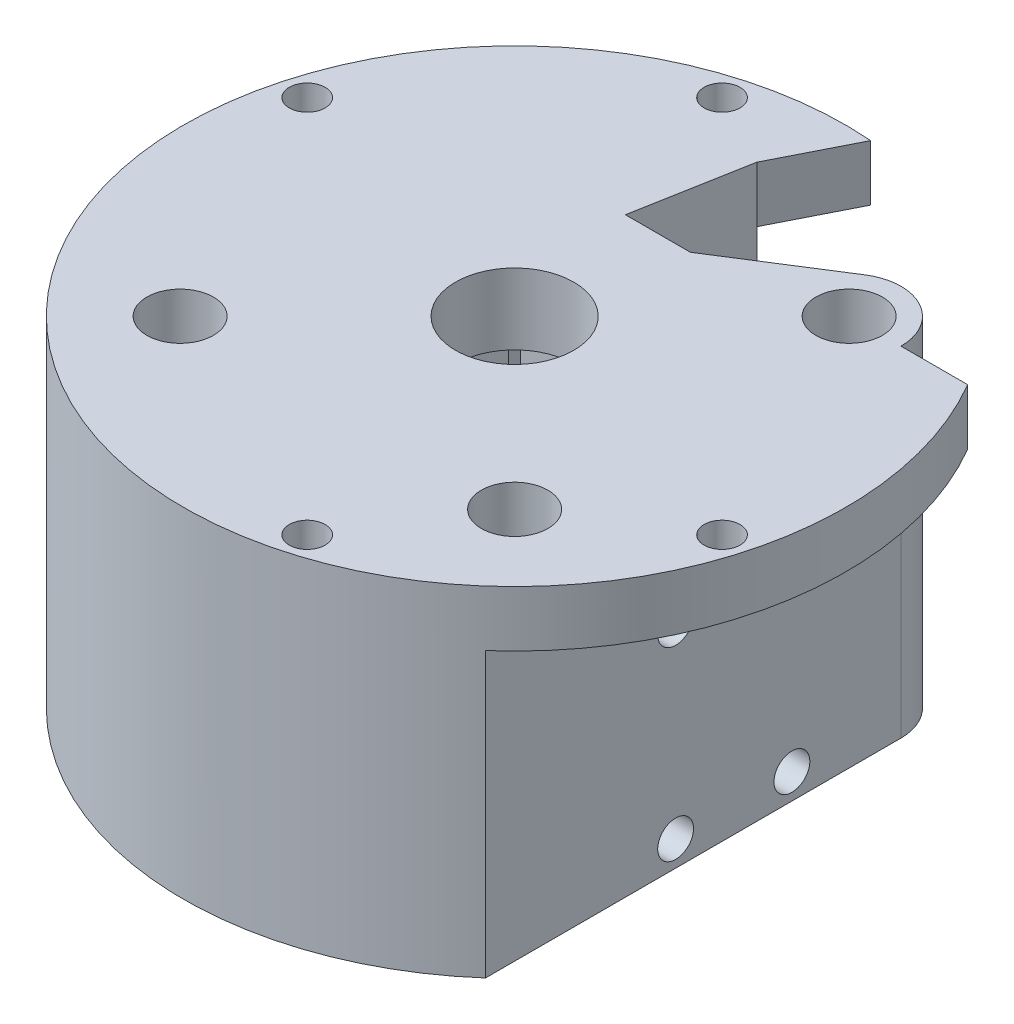
from build123d import *
from build123d.topology import SkipClean

# Parameters (mm, degrees)
SKETCH2_R           = 3.571875
BOSS_EXTRUDE1_DEPTH = 1.905
SKETCH3_R           = 3.571875
BOSS_EXTRUDE2_DEPTH = 19.558
SKETCH4_R           = 3.571875
BOSS_EXTRUDE3_DEPTH = 7.366
SKETCH5_R           = 3.571875
BOSS_EXTRUDE4_DEPTH = 7.62
SKETCH6_R           = 1.925
CUT_EXTRUDE1_DEPTH  = 5.75
BOSS_EXTRUDE5_START = -6
BOSS_EXTRUDE5_DEPTH = 6
SKETCH7_R           = 1.925
CUT_EXTRUDE2_DEPTH  = 5.75


with BuildPart() as part:
    # Sketch2 → Boss-Extrude1 (new body)
    with BuildSketch(Plane(origin=(0, 0, 0), x_dir=(1, 0, 0), z_dir=(0, 1, 0))):
        with BuildLine():
            Line((10.05, -30.05), (-10.05, -30.05))
            Line((-10.05, -30.05), (-10.05, 10.05))
            Line((-10.05, 10.05), (-3.4925, 10.05))
            Line((-3.4925, 10.05), (-3.4925, 15.384))
            Line((-3.4925, 15.384), (-1.318232079, 27.330889022))
            Line((-1.318232079, 27.330889022), (-10.839769253, 32.141975578))
            Line((-10.839769253, 32.141975578), (-12.849275114, 33.15734804))
            ThreePointArc((-12.849275114, 33.15734804), (-30.38177824, -18.478667457), (23.532387242, -26.659714002))
            Line((23.532387242, -26.659714002), (23.532387242, -17.960512242))
            Line((23.532387242, -17.960512242), (23.532387242, 17.960512242))
            ThreePointArc((23.532387242, 17.960512242), (20.645690581, 22.842684741), (14.976700581, 22.666110928))
            Line((14.976700581, 22.666110928), (3.4925, 15.384))
            Line((3.4925, 15.384), (3.4925, 10.05))
            Line((3.4925, 10.05), (10.05, 10.05))
            Line((10.05, 10.05), (10.05, -30.05))
        make_face()
        with Locations(Location((17.960512242, 17.960512242, 0), (0, 0, 90))):
            Circle(SKETCH2_R, mode=Mode.SUBTRACT)
        with Locations(Location((17.960512242, -17.960512242, 0), (0, 0, 90))):
            Circle(SKETCH2_R, mode=Mode.SUBTRACT)
        with Locations(Location((-17.960512242, -17.960512242, 0), (0, 0, 90))):
            Circle(SKETCH2_R, mode=Mode.SUBTRACT)
    extrude(amount=BOSS_EXTRUDE1_DEPTH)

    # Sketch3 → Boss-Extrude2 (add)
    # profile 1 of 2: a face of its own
    with SkipClean():  # the faces are left unmerged after this step: merging them gives an invalid solid
        with BuildSketch(Plane(origin=(0, 1.905, 0), x_dir=(1, 0, 0), z_dir=(0, 1, 0))):
            with BuildLine():
                Line((-10.839769253, 32.141975578), (-32.833307795, -11.385051501))
                Line((-32.833307795, -11.385051501), (-23.311770621, -16.196138057))
                Line((-23.311770621, -16.196138057), (-10.3363742, 9.483241835))
                ThreePointArc((-10.3363742, 9.483241835), (-10.197196408, 9.432296011), (-10.05, 9.415))
                Line((-10.05, 9.415), (-10.05, -30.05))
                Line((-10.05, -30.05), (10.05, -30.05))
                Line((10.05, -30.05), (10.05, 10.05))
                Line((10.05, 10.05), (3.4925, 10.05))
                Line((3.4925, 10.05), (3.4925, 15.384))
                Line((3.4925, 15.384), (14.976700581, 22.666110928))
                ThreePointArc((14.976700581, 22.666110928), (20.645690581, 22.842684741), (23.532387242, 17.960512242))
                Line((23.532387242, 17.960512242), (23.532387242, -26.659714002))
                ThreePointArc((23.532387242, -26.659714002), (-30.38177824, -18.478667457), (-12.849275114, 33.15734804))
                Line((-12.849275114, 33.15734804), (-10.839769253, 32.141975578))
            make_face()
            with Locations(Location((17.960512242, 17.960512242, 0), (0, 0, 90))):
                Circle(SKETCH3_R, mode=Mode.SUBTRACT)
            with Locations(Location((17.960512242, -17.960512242, 0), (0, 0, 90))):
                Circle(SKETCH3_R, mode=Mode.SUBTRACT)
            with Locations(Location((-17.960512242, -17.960512242, 0), (0, 0, 90))):
                Circle(SKETCH3_R, mode=Mode.SUBTRACT)
        # profile 2 of 2: a face of its own
        with BuildSketch(Plane(origin=(0, 1.905, 0), x_dir=(1, 0, 0), z_dir=(0, 1, 0))):
            with BuildLine():
                Line((-1.318232079, 27.330889022), (-9.7636258, 10.616758165))
                ThreePointArc((-9.7636258, 10.616758165), (-9.509133743, 10.382699101), (-9.415, 10.05))
                Line((-9.415, 10.05), (-3.4925, 10.05))
                Line((-3.4925, 10.05), (-3.4925, 15.384))
                Line((-3.4925, 15.384), (-1.318232079, 27.330889022))
            make_face()
        extrude(amount=BOSS_EXTRUDE2_DEPTH)

    # Sketch4 → Boss-Extrude3 (add)
    with SkipClean():  # the faces are left unmerged after this step: merging them gives an invalid solid
        with BuildSketch(Plane(origin=(0, 21.463, 0), x_dir=(1, 0, 0), z_dir=(0, 1, 0))):
            with BuildLine():
                Line((0, 10.05), (-3.4925, 10.05))
                Line((-3.4925, 10.05), (-9.415, 10.05))
                ThreePointArc((-9.415, 10.05), (-9.509133743, 10.382699101), (-9.7636258, 10.616758165))
                Line((-9.7636258, 10.616758165), (-1.318232079, 27.330889022))
                Line((-1.318232079, 27.330889022), (-3.4925, 15.384))
                Line((-3.4925, 15.384), (3.4925, 15.384))
                Line((3.4925, 15.384), (14.976700581, 22.666110928))
                ThreePointArc((14.976700581, 22.666110928), (20.645690581, 22.842684741), (23.532387242, 17.960512242))
                Line((23.532387242, 17.960512242), (23.532387242, -26.659714002))
                ThreePointArc((23.532387242, -26.659714002), (-30.38177824, -18.478667457), (-12.849275114, 33.15734804))
                Line((-12.849275114, 33.15734804), (-10.839769253, 32.141975578))
                Line((-10.839769253, 32.141975578), (-32.833307795, -11.385051501))
                Line((-32.833307795, -11.385051501), (-23.311770621, -16.196138057))
                Line((-23.311770621, -16.196138057), (-10.3363742, 9.483241835))
                ThreePointArc((-10.3363742, 9.483241835), (-10.197196408, 9.432296011), (-10.05, 9.415))
                Line((-10.05, 9.415), (-10.05, -30.05))
                Line((-10.05, -30.05), (10.05, -30.05))
                Line((10.05, -30.05), (10.05, 10.05))
                Line((10.05, 10.05), (3.4925, 10.05))
                Line((3.4925, 10.05), (0, 10.05))
            make_face()
            with Locations(Location((17.960512242, 17.960512242, 0), (0, 0, 90))):
                Circle(SKETCH4_R, mode=Mode.SUBTRACT)
            with Locations(Location((17.960512242, -17.960512242, 0), (0, 0, 90))):
                Circle(SKETCH4_R, mode=Mode.SUBTRACT)
            with Locations(Location((-17.960512242, -17.960512242, 0), (0, 0, 90))):
                Circle(SKETCH4_R, mode=Mode.SUBTRACT)
        extrude(amount=BOSS_EXTRUDE3_DEPTH)

    # Sketch5 → Boss-Extrude4 (add)
    with SkipClean():  # the faces are left unmerged after this step: merging them gives an invalid solid
        with BuildSketch(Plane(origin=(0, 28.829, 0), x_dir=(1, 0, 0), z_dir=(0, 1, 0))):
            with BuildLine():
                Line((3.4925, 15.384), (-3.4925, 15.384))
                Line((-3.4925, 15.384), (-1.318232079, 27.330889022))
                Line((-1.318232079, 27.330889022), (-12.849275114, 33.15734804))
                ThreePointArc((-12.849275114, 33.15734804), (-30.38177824, -18.478667457), (23.532387242, -26.659714002))
                Line((23.532387242, -26.659714002), (23.532387242, 17.960512242))
                ThreePointArc((23.532387242, 17.960512242), (20.645690581, 22.842684741), (14.976700581, 22.666110928))
                Line((14.976700581, 22.666110928), (3.4925, 15.384))
            make_face()
            with Locations(Location((17.960512242, 17.960512242, 0), (0, 0, 90))):
                Circle(SKETCH5_R, mode=Mode.SUBTRACT)
            with Locations(Location((17.960512242, -17.960512242, 0), (0, 0, 90))):
                Circle(SKETCH5_R, mode=Mode.SUBTRACT)
            with Locations(Location((-17.960512242, -17.960512242, 0), (0, 0, 90))):
                Circle(SKETCH5_R, mode=Mode.SUBTRACT)
            with BuildLine():
                ThreePointArc((4.490128061, 4.490128061), (0, 6.35), (-4.490128061, 4.490128061))
                ThreePointArc((-4.490128061, 4.490128061), (0, -6.35), (4.490128061, 4.490128061))
            make_face(mode=Mode.SUBTRACT)
        extrude(amount=BOSS_EXTRUDE4_DEPTH)

    # Sketch6 → Cut-Extrude1 (cut)
    with SkipClean():  # the faces are left unmerged after this step: merging them gives an invalid solid
        with BuildSketch(Plane(origin=(23.532387242, 0, 0), x_dir=(0, 0, -1), z_dir=(1, 0, 0))):
            with Locations((-6.243, 22.65775)):
                Circle(SKETCH6_R)
            with Locations((6.243, 22.65775)):
                Circle(SKETCH6_R)
            with Locations((6.243, 2.74225)):
                Circle(SKETCH6_R)
            with Locations((-6.243, 2.74225)):
                Circle(SKETCH6_R)
        extrude(amount=-CUT_EXTRUDE1_DEPTH, mode=Mode.SUBTRACT)

    # Sketch8 → Boss-Extrude5 (add)
    with SkipClean():  # the faces are left unmerged after this step: merging them gives an invalid solid
        with BuildSketch(Plane(origin=(0, 36.449, 0), x_dir=(1, 0, 0), z_dir=(0, 1, 0)).offset(BOSS_EXTRUDE5_START)):
            with BuildLine():
                Line((-1.318232079, 27.330889022), (-12.849275114, 33.15734804))
                ThreePointArc((-12.849275114, 33.15734804), (-5.161320145, 35.183438922), (2.78463559, 35.450802595))
                Line((2.78463559, 35.450802595), (-1.318232079, 27.330889022))
            make_face()
            with BuildLine():
                Line((23.532387242, 17.960512242), (30.690936773, 17.960512242))
                ThreePointArc((30.690936773, 17.960512242), (35.111014858, -5.63295976), (23.532387242, -26.659714002))
                Line((23.532387242, -26.659714002), (23.532387242, -17.960512242))
                Line((23.532387242, -17.960512242), (23.532387242, 17.960512242))
            make_face()
        extrude(amount=BOSS_EXTRUDE5_DEPTH)

    # Sketch7 → Cut-Extrude2 (cut)
    with SkipClean():  # the faces are left unmerged after this step: merging them gives an invalid solid
        with BuildSketch(Plane(origin=(0, 36.449, 0), x_dir=(1, 0, 0), z_dir=(0, 1, 0))):
            with Locations(Location((-31.466251763, 9.192388155, 0), (0, 0, 270))):
                Circle(SKETCH7_R)
            with Locations(Location((-9.192388155, 31.466251763, 0), (0, 0, 270))):
                Circle(SKETCH7_R)
            with Locations(Location((31.466251763, -9.192388155, 0), (0, 0, 270))):
                Circle(SKETCH7_R)
            with Locations(Location((9.192388155, -31.466251763, 0), (0, 0, 270))):
                Circle(SKETCH7_R)
        extrude(amount=-CUT_EXTRUDE2_DEPTH, mode=Mode.SUBTRACT)


solid = part.part
